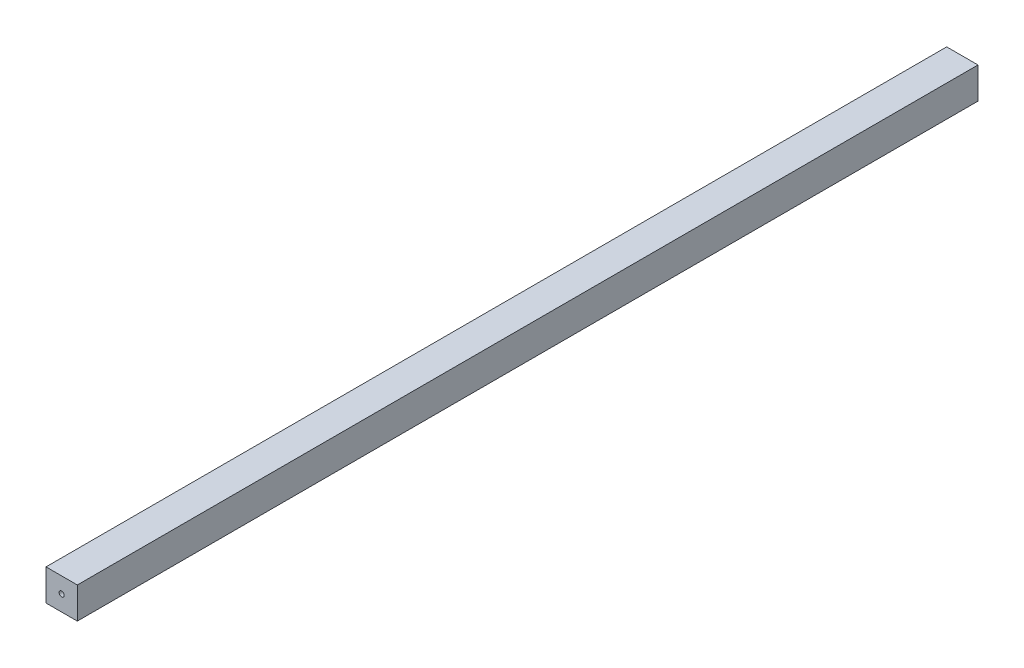
from build123d import *

# Parameters (mm, degrees)
SKETCH1_W           = 25.4
SKETCH1_H           = 25.4
BOSS_EXTRUDE1_DEPTH = 365.125
SKETCH2_R           = 2.0828
CUT_EXTRUDE1_DEPTH  = 812.292


with BuildPart() as part:
    # Sketch1 → Boss-Extrude1 (new body, symmetric)
    with BuildSketch(Plane.XY):
        Rectangle(SKETCH1_W, SKETCH1_H)
    extrude(amount=BOSS_EXTRUDE1_DEPTH, both=True)

    # Sketch2 → Cut-Extrude1 (cut)
    with BuildSketch(Plane.XY.offset(365.125)):
        Circle(SKETCH2_R)
    extrude(amount=-CUT_EXTRUDE1_DEPTH, mode=Mode.SUBTRACT)


solid = part.part
